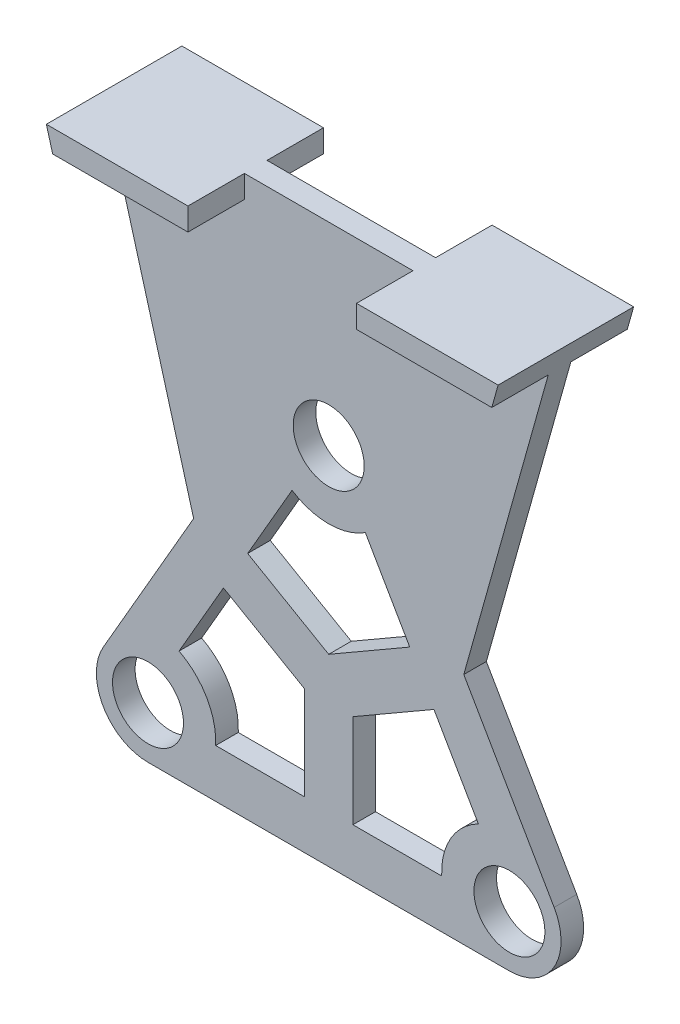
from build123d import *

# Parameters (mm, degrees)
SKETCH1_R           = 11
BOSS_EXTRUDE1_DEPTH = 7
CUT_EXTRUDE1_DEPTH  = 8
BOSS_EXTRUDE2_DEPTH = 7
BOSS_EXTRUDE3_DEPTH = 17.5
BOSS_EXTRUDE4_DEPTH = 17.5
SKETCH10_W          = 52.24
SKETCH10_H          = 17.5
CUT_EXTRUDE2_DEPTH  = 173.994845224


with BuildPart() as part:
    # Sketch1 → Boss-Extrude1 (new body)
    with BuildSketch(Plane.XY):
        with BuildLine():
            Line((42.143593539, 104.994845224), (-13.856406461, 8))
            ThreePointArc((-13.856406461, 8), (-13.856406461, -8), (0, -16))
            Line((0, -16), (112, -16))
            ThreePointArc((112, -16), (125.856406461, -8), (125.856406461, 8))
            Line((125.856406461, 8), (69.856406461, 104.994845224))
            ThreePointArc((69.856406461, 104.994845224), (56, 112.994845224), (42.143593539, 104.994845224))
        make_face()
        Circle(SKETCH1_R, mode=Mode.SUBTRACT)
        with Locations((112, 0)):
            Circle(SKETCH1_R, mode=Mode.SUBTRACT)
        with Locations((56, 96.994845224)):
            Circle(SKETCH1_R, mode=Mode.SUBTRACT)
    extrude(amount=BOSS_EXTRUDE1_DEPTH)

    # Sketch2 → Cut-Extrude1 (cut, through all)
    with BuildSketch(Plane.XY.offset(7)):
        with BuildLine():
            Line((9.622063078, 18.665902125), (23.383974596, 42.502232084))
            Line((23.383974596, 42.502232084), (48.5, 28.001488056))
            Line((48.5, 28.001488056), (48.5, -1))
            Line((48.5, -1), (20.976176963, -1))
            ThreePointArc((20.976176963, -1), (18.186533479, 10.5), (9.622063078, 18.665902125))
        make_face()
        with BuildLine():
            Line((63.5, -1), (91.023823037, -1))
            ThreePointArc((91.023823037, -1), (93.813466521, 10.5), (102.377936922, 18.665902125))
            Line((102.377936922, 18.665902125), (88.616025404, 42.502232084))
            Line((88.616025404, 42.502232084), (63.5, 28.001488056))
            Line((63.5, 28.001488056), (63.5, -1))
        make_face()
        with BuildLine():
            Line((30.883974596, 55.49261314), (44.645886115, 79.328943099))
            ThreePointArc((44.645886115, 79.328943099), (56, 75.994845224), (67.354113885, 79.328943099))
            Line((67.354113885, 79.328943099), (81.116025404, 55.49261314))
            Line((81.116025404, 55.49261314), (56, 40.991869112))
            Line((56, 40.991869112), (30.883974596, 55.49261314))
        make_face()
    extrude(amount=-CUT_EXTRUDE1_DEPTH, mode=Mode.SUBTRACT)

    # Sketch7 → Boss-Extrude2 (add)
    with BuildSketch(Plane.XY):
        with BuildLine():
            Line((-14, 156.994845224), (126, 156.994845224))
            Line((126, 156.994845224), (97.856406461, 56.497422612))
            Line((97.856406461, 56.497422612), (69.856406461, 104.994845224))
            ThreePointArc((69.856406461, 104.994845224), (56, 112.994845224), (42.143593539, 104.994845224))
            Line((42.143593539, 104.994845224), (14.143593539, 56.497422612))
            Line((14.143593539, 56.497422612), (-14, 156.994845224))
        make_face()
    extrude(amount=BOSS_EXTRUDE2_DEPTH)

    # Sketch8 → Boss-Extrude3 (add)
    with BuildSketch(Plane.XY.offset(7)):
        Polygon((-12.039699431, 149.994845224), (124.039699431, 149.994845224), (126, 156.994845224), (-14, 156.994845224), align=None)
    extrude(amount=BOSS_EXTRUDE3_DEPTH)

    # Sketch9 → Boss-Extrude4 (add)
    with BuildSketch(Plane(origin=(0, 0, 0), x_dir=(-1, 0, 0), z_dir=(0, 0, -1))):
        Polygon((-124.039699431, 149.994845224), (12.039699431, 149.994845224), (14, 156.994845224), (-126, 156.994845224), align=None)
    extrude(amount=BOSS_EXTRUDE4_DEPTH)

    # Sketch10 → Cut-Extrude2 (cut, through all)
    with BuildSketch(Plane(origin=(0, 156.994845224, 0), x_dir=(1, 0, 0), z_dir=(0, 1, 0))):
        with Locations((56, -15.75)):
            Rectangle(SKETCH10_W, SKETCH10_H)
        with Locations((56, 8.75)):
            Rectangle(SKETCH10_W, SKETCH10_H)
    extrude(amount=-CUT_EXTRUDE2_DEPTH, mode=Mode.SUBTRACT)


solid = part.part
